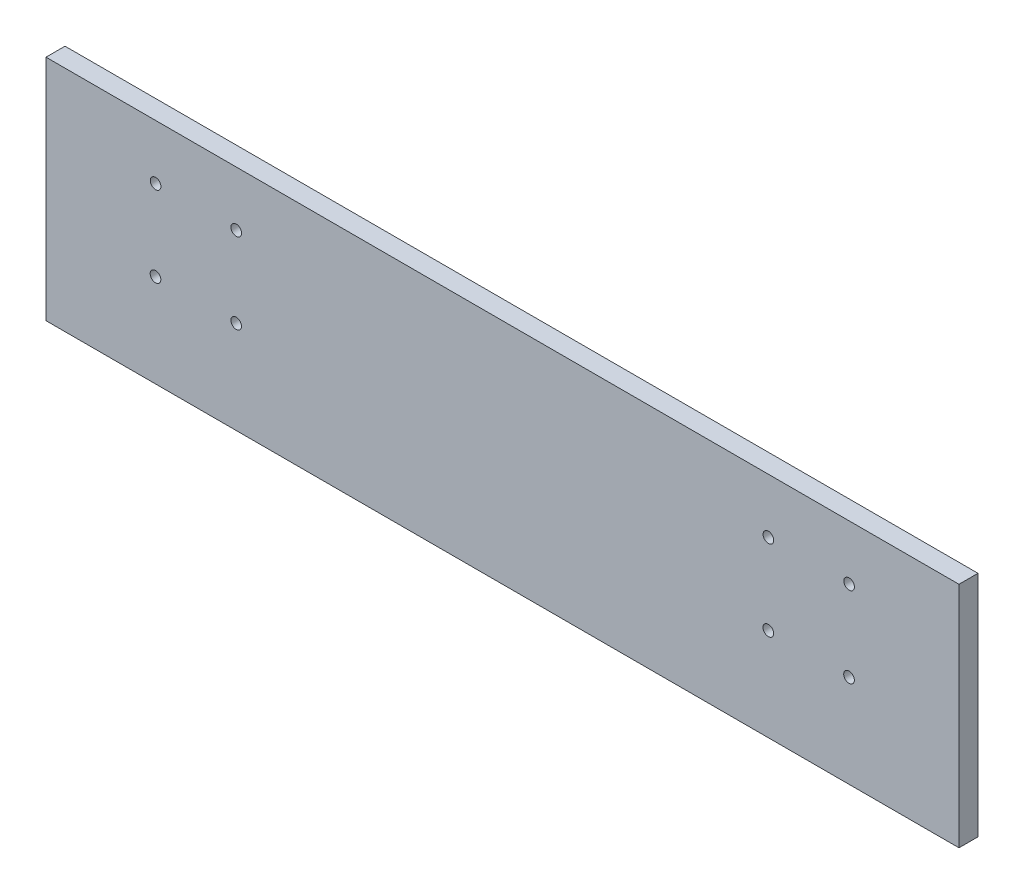
from build123d import *

# Parameters (mm, degrees)
SKETCH1_W           = 304.8
SKETCH1_H           = 76.2
BOSS_EXTRUDE1_DEPTH = 6.35
SKETCH2_R           = 1.778
CUT_EXTRUDE1_DEPTH  = 10.16


with BuildPart() as part:
    # Sketch1 → Boss-Extrude1 (new body)
    with BuildSketch(Plane.XY):
        with Locations((152.4, 38.1)):
            Rectangle(SKETCH1_W, SKETCH1_H)
    extrude(amount=BOSS_EXTRUDE1_DEPTH)

    # Sketch2 → Cut-Extrude1 (cut)
    with BuildSketch(Plane(origin=(0, 0, 0), x_dir=(-1, 0, 0), z_dir=(0, 0, -1))):
        with Locations((-268.116614175, 57.937084818)):
            Circle(SKETCH2_R)
        with Locations((-241.175855182, 57.959554175)):
            Circle(SKETCH2_R)
        with Locations((-241.153385825, 31.018795182)):
            Circle(SKETCH2_R)
        with Locations((-268.094144818, 30.996325825)):
            Circle(SKETCH2_R)
        with Locations((-36.578855182, 57.959554175)):
            Circle(SKETCH2_R)
        with Locations((-63.519614175, 57.937084818)):
            Circle(SKETCH2_R)
        with Locations((-63.497144818, 30.996325825)):
            Circle(SKETCH2_R)
        with Locations((-36.556385825, 31.018795182)):
            Circle(SKETCH2_R)
    extrude(amount=-CUT_EXTRUDE1_DEPTH, mode=Mode.SUBTRACT)


solid = part.part
